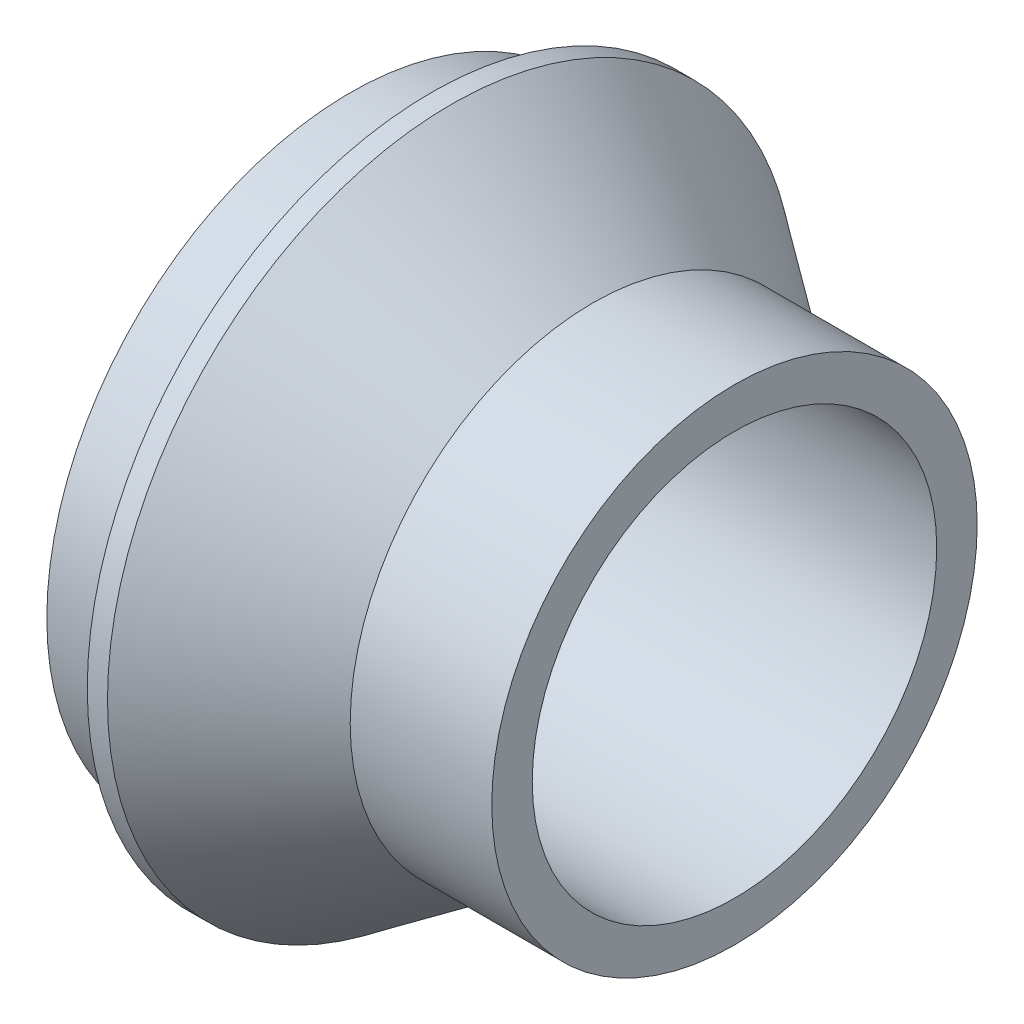
from build123d import *


with BuildPart() as part:
    # Szkic1 → Obrót1 (revolve)
    with BuildSketch(Plane.XY):
        Polygon((4, 15), (0, 15), (0, 13), (4, 13), (4, 10), (19, 10), (19, 12), (12, 12), (5, 17), (4, 17), align=None)
    revolve(axis=Axis((0, 0, 0), (1, 0, 0)))


solid = part.part
